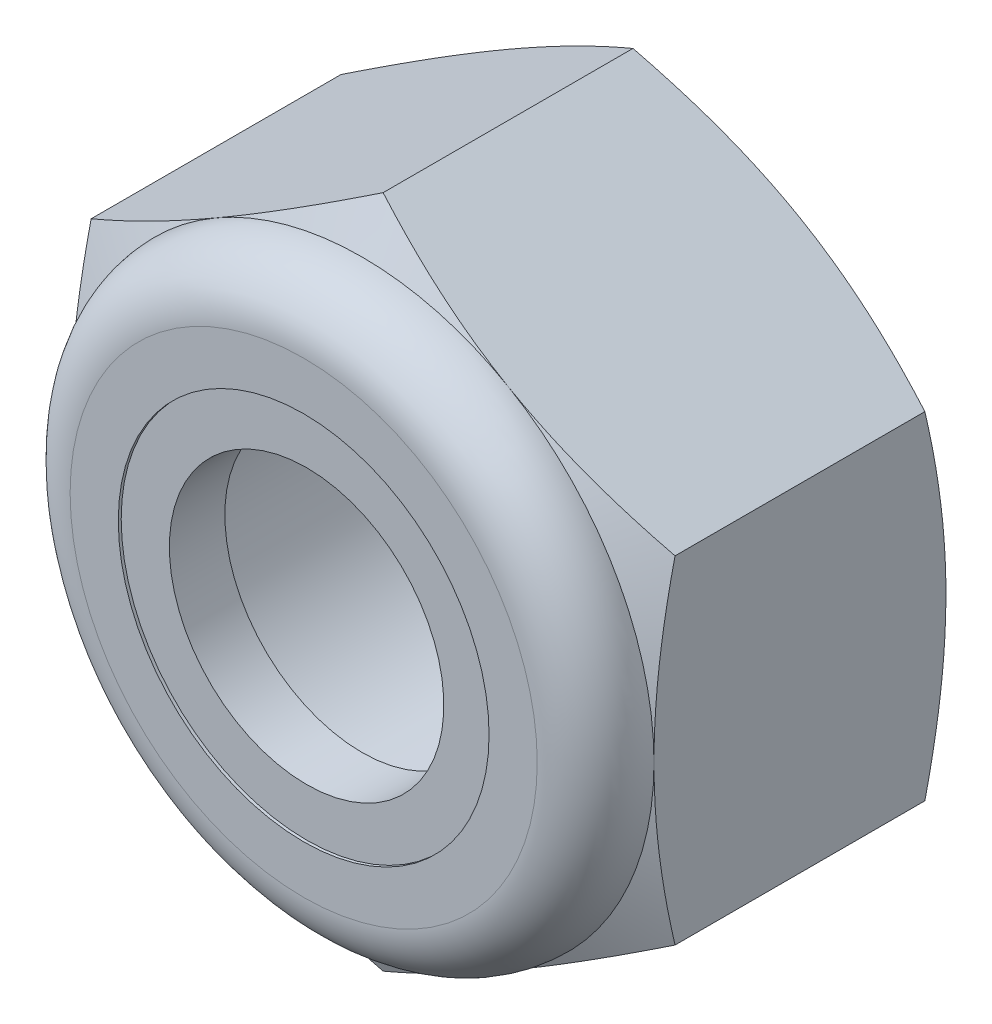
from build123d import *

# Parameters (mm, degrees)
SKETCH3_R           = 3
BOSS_EXTRUDE1_DEPTH = 3


with BuildPart() as part:
    # Sketch3 → Boss-Extrude1 (new body, symmetric)
    with BuildSketch(Plane.XY):
        Polygon((0, -5.773502692), (5, -2.886751346), (5, 2.886751346), (0, 5.773502692), (-5, 2.886751346), (-5, -2.886751346), align=None)
        Circle(SKETCH3_R, mode=Mode.SUBTRACT)
    extrude(amount=BOSS_EXTRUDE1_DEPTH, both=True)

    # Sketch4 → Cut-Revolve1 (revolve, cut)
    with BuildSketch(Plane(origin=(0, 0, 0), x_dir=(0, 0, -1), z_dir=(1, 0, 0))):
        with BuildLine():
            Line((4.27, 7.043502692), (-4.27, 7.043502692))
            Line((-4.27, 7.043502692), (-4.27, 4))
            Line((-4.27, 4), (-3, 4))
            ThreePointArc((-3, 4), (-2.707106781, 4.707106781), (-2, 5))
            Line((-2, 5), (-1.639309771, 5.773502692))
            Line((-1.639309771, 5.773502692), (2.639309771, 5.773502692))
            Line((2.639309771, 5.773502692), (3, 5))
            Line((3, 5), (3, 0))
            Line((3, 0), (4.27, 0))
            Line((4.27, 0), (4.27, 7.043502692))
        make_face()
        with BuildLine():
            Line((-4.27, 3.175240474), (-4.27, 0))
            Line((-4.27, 0), (-2, 0))
            Line((-2, 0), (-2, 4.95))
            ThreePointArc((-2, 4.95), (-2.671751442, 4.671751442), (-2.95, 4))
            Line((-2.95, 4), (-2.95, 3.175240474))
            Line((-2.95, 3.175240474), (-4.27, 3.175240474))
        make_face()
    revolve(axis=Axis((0, 0, -3), (0, 0, 1)), mode=Mode.SUBTRACT)


with BuildPart() as body_2:
    # Sketch5 → Revolve1 (revolve)
    with BuildSketch(Plane(origin=(0, 0, 0), x_dir=(0, 0, -1), z_dir=(1, 0, 0))):
        with BuildLine():
            Line((-2.95, 4), (-2.95, 2.350480947))
            Line((-2.95, 2.350480947), (-2, 2.350480947))
            Line((-2, 2.350480947), (-2, 4.95))
            ThreePointArc((-2, 4.95), (-2.671751442, 4.671751442), (-2.95, 4))
        make_face()
    revolve(axis=Axis((0, 0, -3), (0, 0, 1)))


solid = Compound([part.part, body_2.part])
